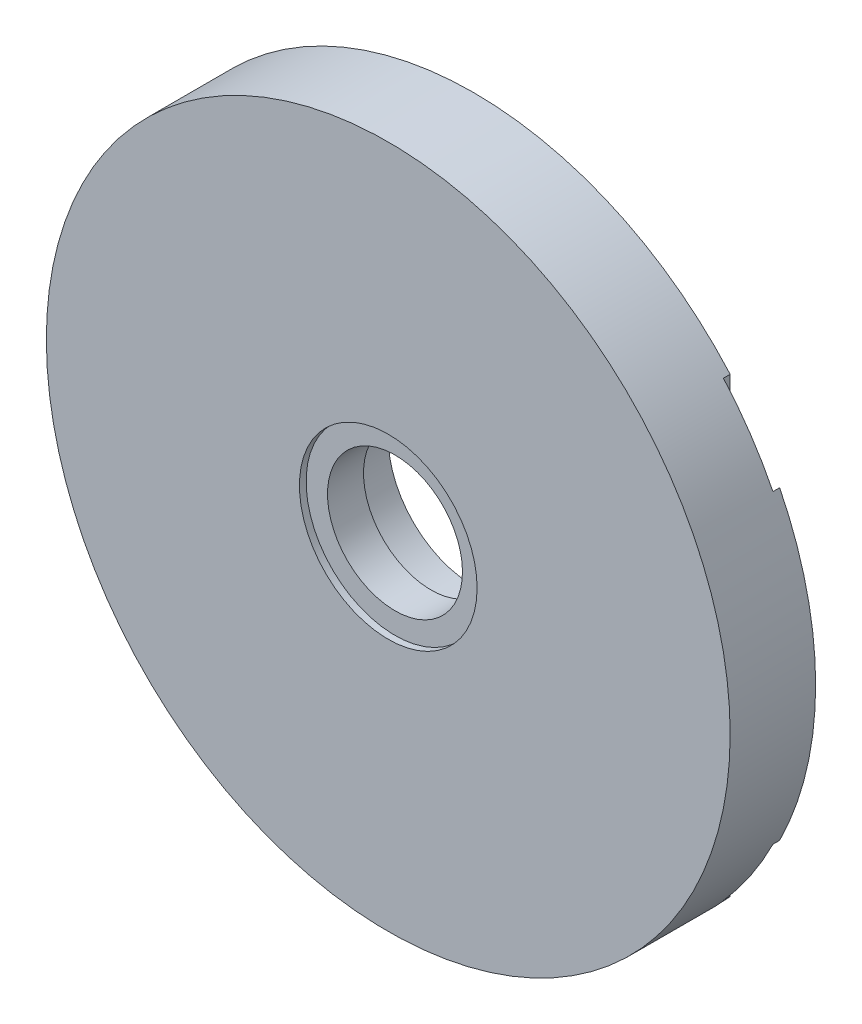
from build123d import *

# Parameters (mm, degrees)
SKETCH1_R           = 50.8
SKETCH1_R_2         = 13.2
SKETCH1_R_3         = 10.025
SKETCH1_R_4         = 12.7
BOSS_EXTRUDE1_DEPTH = 12.7
CUT_EXTRUDE1_START  = 12.7
SKETCH1_3_R         = 13.2
SKETCH1_3_R_2       = 12.7
SKETCH1_3_R_3       = 10.025
CUT_EXTRUDE1_DEPTH  = 1
SKETCH1_4_R         = 12.7
SKETCH1_4_R_2       = 10.025
CUT_EXTRUDE2_DEPTH  = 6.35
CUT_EXTRUDE3_DEPTH  = 1


with BuildPart() as part:
    # Sketch1 → Boss-Extrude1 (new body)
    with BuildSketch(Plane(origin=(0, 0, 0), x_dir=(0, 1, 0), z_dir=(0, 0, 1))):
        with Locations(Location((0, 0, 0), (0, 0, 270))):
            Circle(SKETCH1_R)
        Circle(SKETCH1_R_2, mode=Mode.SUBTRACT)
        Circle(SKETCH1_R_2)
        with Locations(Location((0, 0, 0), (0, 0, 270))):
            Circle(SKETCH1_R_3, mode=Mode.SUBTRACT)
        Circle(SKETCH1_R_4)
        with Locations(Location((0, 0, 0), (0, 0, 270))):
            Circle(SKETCH1_R_3, mode=Mode.SUBTRACT)
    extrude(amount=BOSS_EXTRUDE1_DEPTH)

    # Sketch1_3 → Cut-Extrude1 (cut)
    with BuildSketch(Plane(origin=(0, 0, 0), x_dir=(0, 1, 0), z_dir=(0, 0, 1)).offset(CUT_EXTRUDE1_START)):
        with Locations(Location((0, 0, 0), (0, 0, 270))):
            Circle(SKETCH1_3_R)
        Circle(SKETCH1_3_R_2, mode=Mode.SUBTRACT)
        Circle(SKETCH1_3_R_2)
        with Locations(Location((0, 0, 0), (0, 0, 270))):
            Circle(SKETCH1_3_R_3, mode=Mode.SUBTRACT)
    extrude(amount=-CUT_EXTRUDE1_DEPTH, mode=Mode.SUBTRACT)

    # Sketch1_4 → Cut-Extrude2 (cut)
    with BuildSketch(Plane(origin=(0, 0, 0), x_dir=(0, 1, 0), z_dir=(0, 0, 1))):
        with Locations(Location((0, 0, 0), (0, 0, 270))):
            Circle(SKETCH1_4_R)
        with Locations(Location((0, 0, 0), (0, 0, 270))):
            Circle(SKETCH1_4_R_2, mode=Mode.SUBTRACT)
    extrude(amount=CUT_EXTRUDE2_DEPTH, mode=Mode.SUBTRACT)

    # Sketch2 → Cut-Extrude3 (cut)
    with BuildSketch(Plane(origin=(0, 0, 0), x_dir=(1, 0, 0), z_dir=(0, 0, -1))):
        with BuildLine():
            Line((-38.1, -33.601041651), (-38.1, 0))
            Line((-38.1, 0), (-38.1, 33.601041651))
            ThreePointArc((-38.1, 33.601041651), (-42.129575647, 28.385539555), (-45.45, 22.692234355))
            Line((-45.45, 22.692234355), (-45.45, -22.692234355))
            ThreePointArc((-45.45, -22.692234355), (-42.129575647, -28.385539555), (-38.1, -33.601041651))
        make_face()
        with BuildLine():
            ThreePointArc((45.45, 22.692234355), (42.129575647, 28.385539555), (38.1, 33.601041651))
            Line((38.1, 33.601041651), (38.1, 0))
            Line((38.1, 0), (38.1, -33.601041651))
            ThreePointArc((38.1, -33.601041651), (42.129575647, -28.385539555), (45.45, -22.692234355))
            Line((45.45, -22.692234355), (45.45, 22.692234355))
        make_face()
    extrude(amount=-CUT_EXTRUDE3_DEPTH, mode=Mode.SUBTRACT)


solid = part.part
